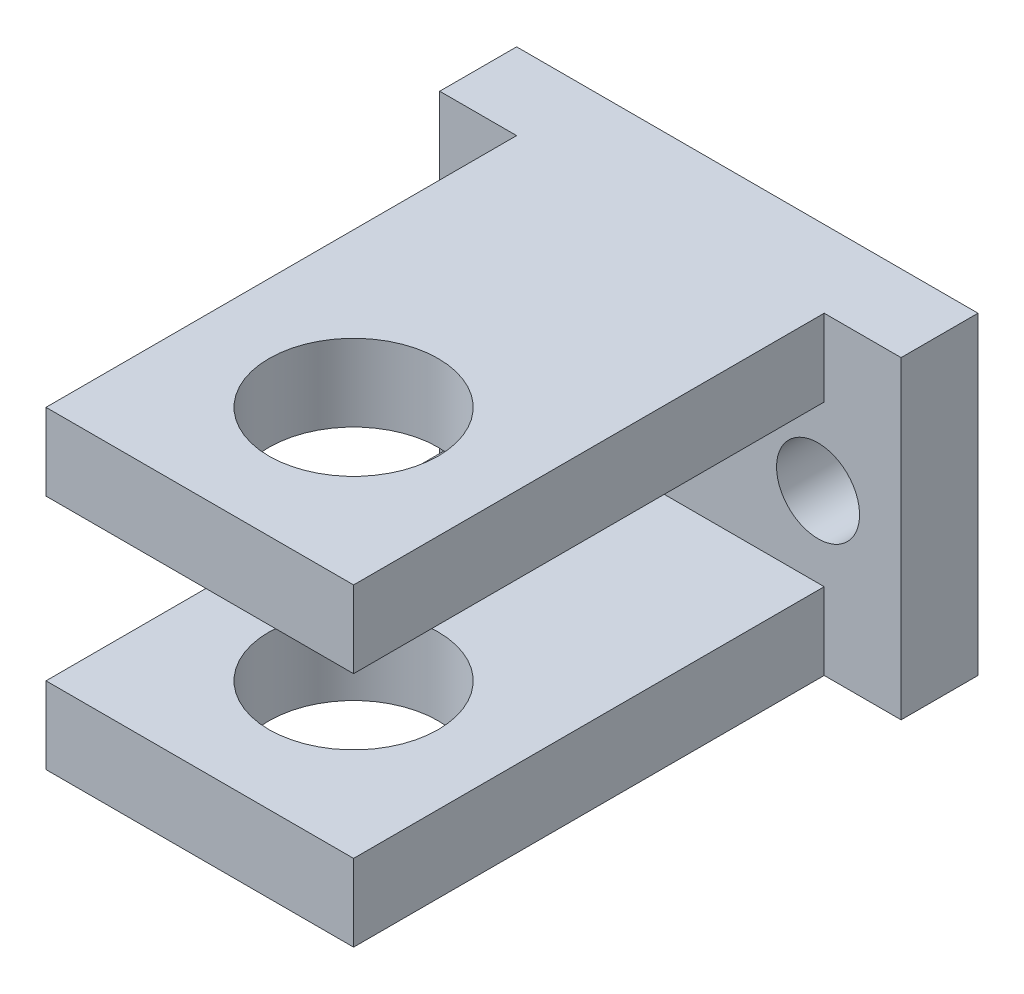
from build123d import *

# Parameters (mm, degrees)
SKETCH1_W                  = 12.7
SKETCH1_H                  = 22.606
BOSS_EXTRUDE1_DEPTH        = 3.175
SKETCH2_W                  = 12.7
SKETCH2_H                  = 3.175
BOSS_EXTRUDE2_DEPTH        = 6.604
SKETCH3_W                  = 12.7
SKETCH3_H                  = 22.606
BOSS_EXTRUDE3_DEPTH        = 3.175
SKETCH4_R                  = 3.4925
CUT_EXTRUDE1_DEPTH         = 13.954
SKETCH6_W                  = 3.175
SKETCH6_H                  = 12.954
BOSS_EXTRUDE4_DEPTH        = 3.175
SKETCH5_R                  = 1.7145
CUT_FOR_MOUNT_SCREWS_DEPTH = 23.606


with BuildPart() as part:
    # Sketch1 → Boss-Extrude1 (new body)
    with BuildSketch(Plane(origin=(0, 0, 0), x_dir=(1, 0, 0), z_dir=(0, 1, 0))):
        Rectangle(SKETCH1_W, SKETCH1_H)
    extrude(amount=BOSS_EXTRUDE1_DEPTH)

    # Sketch2 → Boss-Extrude2 (add)
    with BuildSketch(Plane(origin=(0, 3.175, 0), x_dir=(1, 0, 0), z_dir=(0, 1, 0))):
        with Locations((0, 9.7155)):
            Rectangle(SKETCH2_W, SKETCH2_H)
    extrude(amount=BOSS_EXTRUDE2_DEPTH)

    # Sketch3 → Boss-Extrude3 (add)
    with BuildSketch(Plane(origin=(0, 9.779, 0), x_dir=(1, 0, 0), z_dir=(0, 1, 0))):
        Rectangle(SKETCH3_W, SKETCH3_H)
    extrude(amount=BOSS_EXTRUDE3_DEPTH)

    # Sketch4 → Cut-Extrude1 (cut, through all)
    with BuildSketch(Plane(origin=(0, 12.954, 0), x_dir=(1, 0, 0), z_dir=(0, 1, 0))):
        with Locations((0, -4.953)):
            Circle(SKETCH4_R)
    extrude(amount=-CUT_EXTRUDE1_DEPTH, mode=Mode.SUBTRACT)

    # Sketch6 → Boss-Extrude4 (add)
    with BuildSketch(Plane(origin=(0, 0, -11.303), x_dir=(-1, 0, 0), z_dir=(0, 0, -1))):
        with Locations((-7.9375, 6.477)):
            Rectangle(SKETCH6_W, SKETCH6_H)
        with Locations((7.9375, 6.477)):
            Rectangle(SKETCH6_W, SKETCH6_H)
    extrude(amount=-BOSS_EXTRUDE4_DEPTH)

    # Sketch5 → cut for mount screws (cut, through all)
    with BuildSketch(Plane(origin=(0, 0, -11.303), x_dir=(-1, 0, 0), z_dir=(0, 0, -1))):
        with Locations((6.096, 6.477)):
            Circle(SKETCH5_R)
        with Locations((-6.096, 6.477)):
            Circle(SKETCH5_R)
    extrude(amount=-CUT_FOR_MOUNT_SCREWS_DEPTH, mode=Mode.SUBTRACT)


solid = part.part
